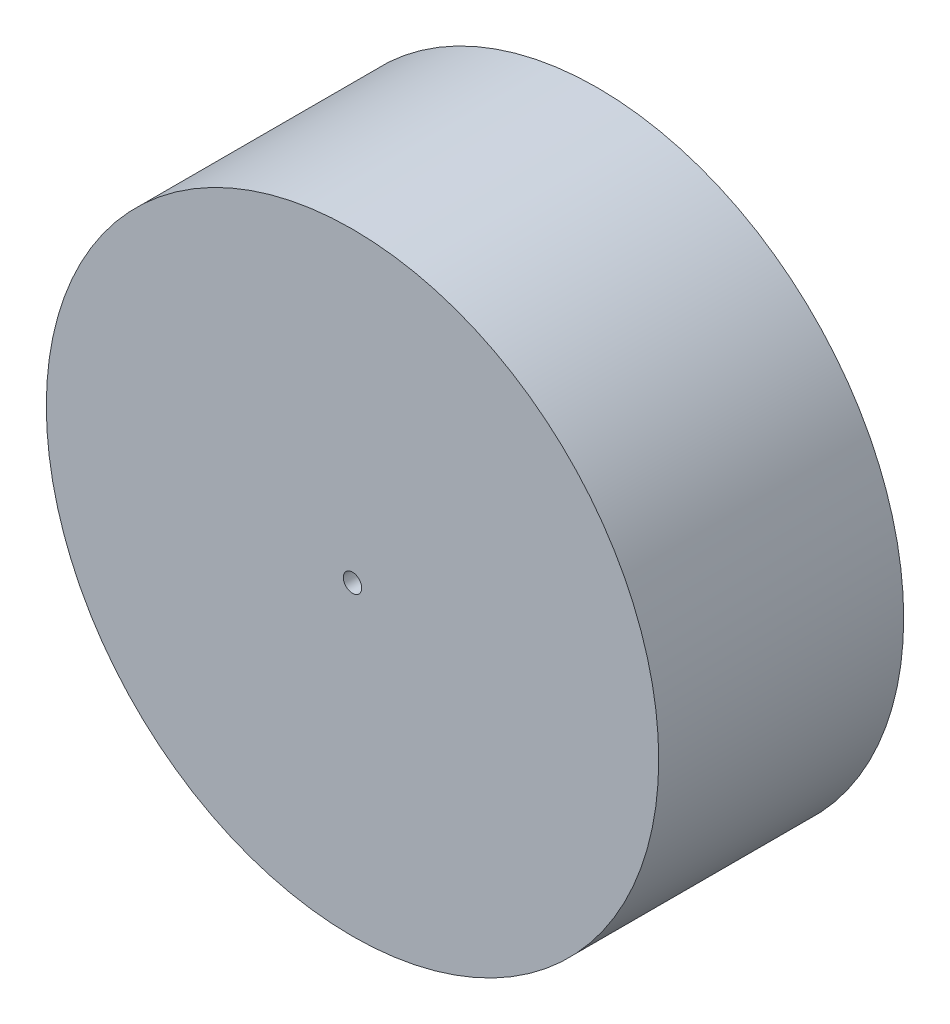
from build123d import *

# Parameters (mm, degrees)
SKETCH1_R           = 50
BOSS_EXTRUDE1_DEPTH = 40
SKETCH2_R           = 30
CUT_EXTRUDE1_DEPTH  = 25
CUT_EXTRUDE2_DEPTH  = 5
SKETCH5_R           = 1.5
CUT_EXTRUDE3_DEPTH  = 40


with BuildPart() as part:
    # Sketch1 → Boss-Extrude1 (new body)
    with BuildSketch(Plane.XY):
        Circle(SKETCH1_R)
    extrude(amount=BOSS_EXTRUDE1_DEPTH)

    # Sketch2 → Cut-Extrude1 (cut)
    with BuildSketch(Plane(origin=(0, 0, 0), x_dir=(-1, 0, 0), z_dir=(0, 0, -1))):
        Circle(SKETCH2_R)
    extrude(amount=-CUT_EXTRUDE1_DEPTH, mode=Mode.SUBTRACT)

    # Sketch3 → Cut-Extrude2 (cut)
    with BuildSketch(Plane(origin=(0, 0, 25), x_dir=(-1, 0, 0), z_dir=(0, 0, -1))):
        Polygon((4.082774554, -4.396697846), (5.849039304, 1.337437558), (1.76626475, 5.734135404), (-4.082774554, 4.396697846), (-5.849039304, -1.337437558), (-1.76626475, -5.734135404), align=None)
    extrude(amount=-CUT_EXTRUDE2_DEPTH, mode=Mode.SUBTRACT)

    # Sketch5 → Cut-Extrude3 (cut)
    with BuildSketch(Plane.XY.offset(40)):
        Circle(SKETCH5_R)
    extrude(amount=-CUT_EXTRUDE3_DEPTH, mode=Mode.SUBTRACT)


solid = part.part
